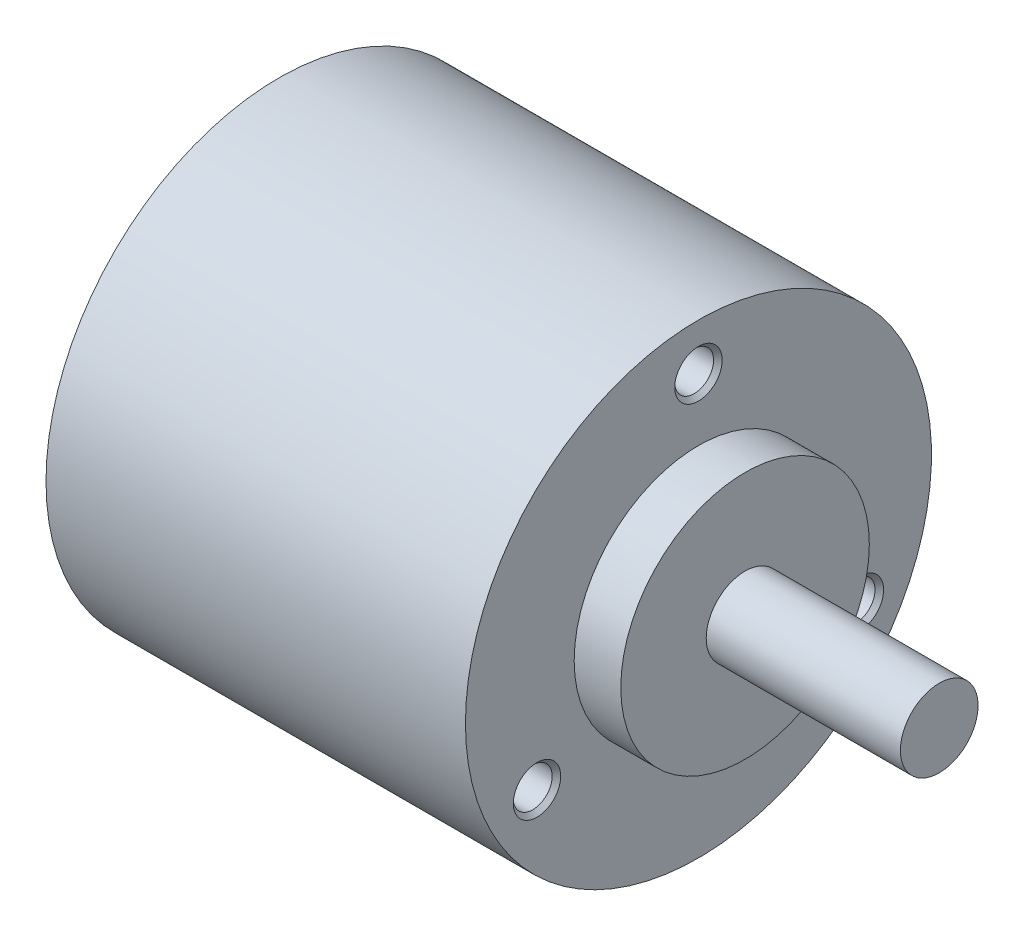
from build123d import *

# Parameters (mm, degrees)
TROU_TARAUD_M3X0_51_D           = 2.5
TROU_TARAUD_M3X0_51_DEPTH       = 8.5
TROU_TARAUD_M3X0_51_CSINK_D     = 3.05
TROU_TARAUD_M3X0_51_CSINK_ANGLE = 90
TROU_TARAUD_M3X0_51_TIP         = 0.751075774


with BuildPart() as part:
    # Esquisse1 → Révolution1 (revolve)
    with BuildSketch(Plane.XY):
        Polygon((15.5, 2.5), (15.5, 0), (-27, 0), (-27, 15), (0, 15), (0, 8), (3, 8), (3, 2.5), align=None)
    revolve(axis=Axis((-51.155053474, 0, 0), (1, 0, 0)))

    # Trou taraudé M3x0.51
    with Locations(Plane(origin=(0, 0, 0), x_dir=(0, 0, -1), z_dir=(1, 0, 0))):
        with Locations((0, 12), (-10.392304845, -6), (10.392304845, -6)):
            CounterSinkHole(TROU_TARAUD_M3X0_51_D / 2, TROU_TARAUD_M3X0_51_CSINK_D / 2, depth=TROU_TARAUD_M3X0_51_DEPTH, counter_sink_angle=TROU_TARAUD_M3X0_51_CSINK_ANGLE)
            with Locations((0, 0, -(TROU_TARAUD_M3X0_51_DEPTH + TROU_TARAUD_M3X0_51_TIP / 2))):  # 118° drill point
                Cone(0, TROU_TARAUD_M3X0_51_D / 2, TROU_TARAUD_M3X0_51_TIP, mode=Mode.SUBTRACT)


solid = part.part
